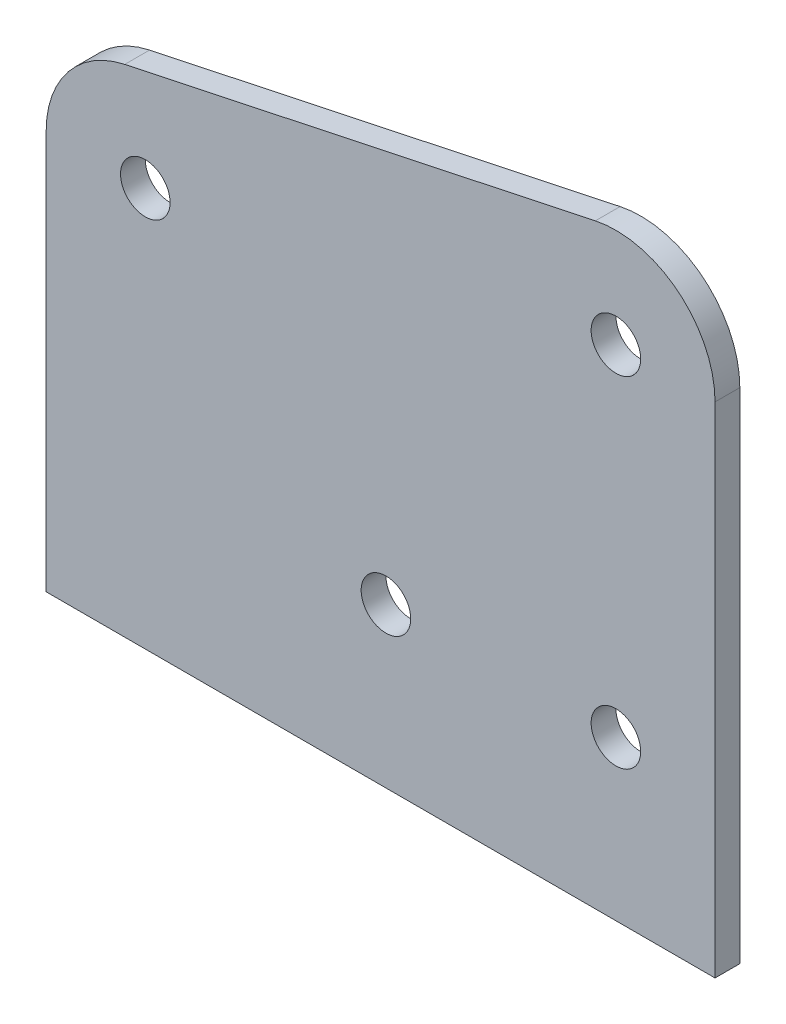
from build123d import *

# Parameters (mm, degrees)
SKETCH1_R           = 3.175
BOSS_EXTRUDE1_DEPTH = 3.175


with BuildPart() as part:
    # Sketch1 → Boss-Extrude1 (new body)
    with BuildSketch(Plane.XY):
        with BuildLine():
            Line((18.052936785, 76.341523137), (-42.240313215, 63.554909137))
            ThreePointArc((-42.240313215, 63.554909137), (-49.473481519, 59.125864726), (-52.305574358, 51.131216))
            Line((-52.305574358, 51.131216), (-52.305574358, 0))
            Line((-52.305574358, 0), (33.387675642, 0))
            Line((33.387675642, 0), (33.387675642, 63.91783))
            ThreePointArc((33.387675642, 63.91783), (28.682324369, 73.785737161), (18.052936785, 76.341523137))
        make_face()
        with Locations((20.687675642, 20.35683)):
            Circle(SKETCH1_R, mode=Mode.SUBTRACT)
        with Locations((20.687675642, 63.91783)):
            Circle(SKETCH1_R, mode=Mode.SUBTRACT)
        with Locations((-8.776324358, 20.35683)):
            Circle(SKETCH1_R, mode=Mode.SUBTRACT)
        with Locations((-39.605574358, 51.131216)):
            Circle(SKETCH1_R, mode=Mode.SUBTRACT)
    extrude(amount=BOSS_EXTRUDE1_DEPTH)


solid = part.part
